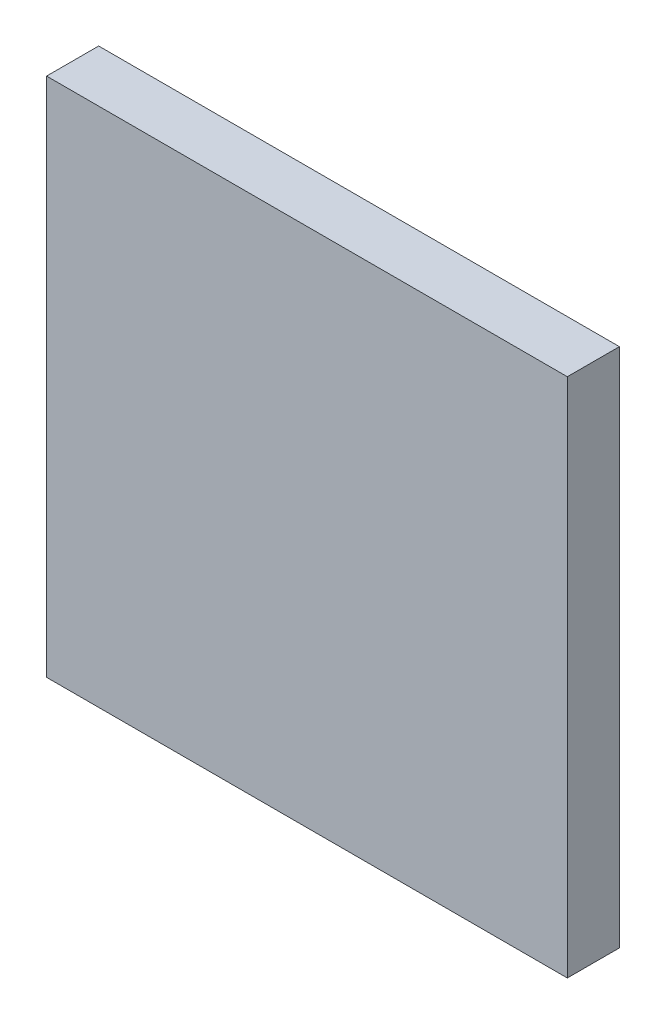
from build123d import *

# Parameters (mm, degrees)
SKETCH1_W           = 508
SKETCH1_H           = 508
BOSS_EXTRUDE1_DEPTH = 50.8


with BuildPart() as part:
    # Sketch1 → Boss-Extrude1 (new body)
    with BuildSketch(Plane.XY):
        with Locations((-254, 254)):
            Rectangle(SKETCH1_W, SKETCH1_H)
    extrude(amount=BOSS_EXTRUDE1_DEPTH)


solid = part.part
